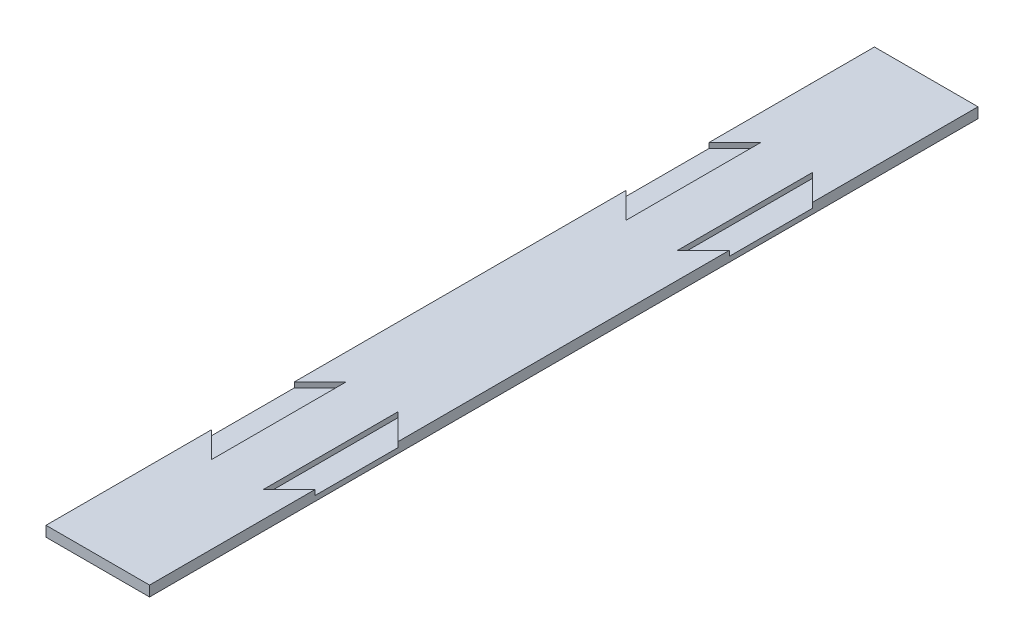
from build123d import *

# Parameters (mm, degrees)
SKETCH1_W           = 25.4
SKETCH1_H           = 203.2
BOSS_EXTRUDE1_DEPTH = 2.54
CUT_EXTRUDE1_DEPTH  = 1.27


with BuildPart() as part:
    # Sketch1 → Boss-Extrude1 (new body)
    with BuildSketch(Plane(origin=(0, 0, 0), x_dir=(1, 0, 0), z_dir=(0, 1, 0))):
        Rectangle(SKETCH1_W, SKETCH1_H)
    extrude(amount=-BOSS_EXTRUDE1_DEPTH)

    # Sketch3 → Cut-Extrude1 (cut)
    with BuildSketch(Plane(origin=(0, 0, 0), x_dir=(1, 0, 0), z_dir=(0, 1, 0))):
        Polygon((12.7, 40.64), (6.35, 34.29), (6.35, 67.31), (12.7, 60.96), align=None)
        Polygon((-6.35, 67.31), (-12.7, 60.96), (-12.7, 40.64), (-6.35, 34.29), align=None)
        Polygon((6.35, -67.31), (12.7, -60.96), (12.7, -40.64), (6.35, -34.29), align=None)
        Polygon((-6.35, -34.29), (-6.35, -67.31), (-12.7, -60.96), (-12.7, -40.64), align=None)
    extrude(amount=-CUT_EXTRUDE1_DEPTH, mode=Mode.SUBTRACT)


solid = part.part
